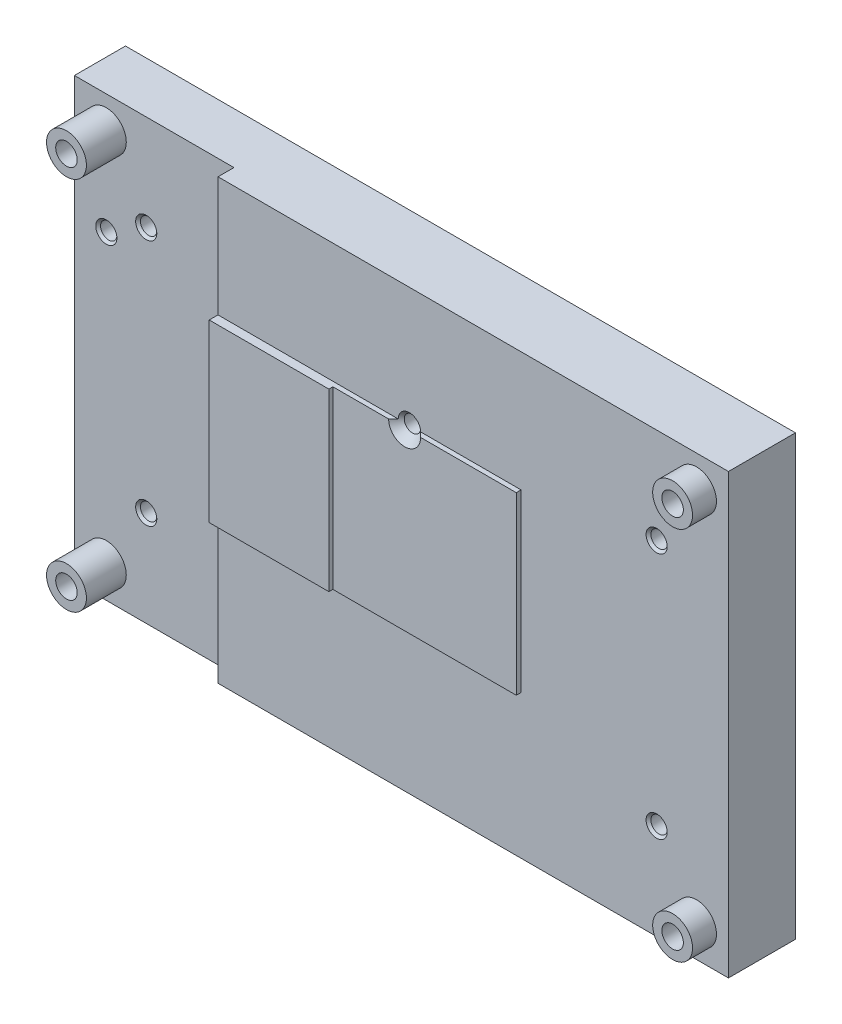
from build123d import *

# Parameters (mm, degrees)
SKETCH1_W                               = 84
SKETCH1_H                               = 55
EXTRUDE1_DEPTH                          = 11.4
F_2_7_2_7_DIAMETER_HOLE1_D              = 2.7
SKETCH6_OUTSIDE_W                       = 106.21
SKETCH6_OUTSIDE_H                       = 77.21
SKETCH6_OUTSIDE_R                       = 2.5
EXTRUDE2_DEPTH                          = 3
SKETCH7_W                               = 15
SKETCH7_H                               = 22
EXTRUDE3_DEPTH                          = 1.1
SKETCH8_W                               = 26.471562954
SKETCH8_H                               = 62.575334395
SKETCH8_R                               = 2.5
EXTRUDE6_DEPTH                          = 2
SKETCH9_W                               = 23
SKETCH9_H                               = 22
EXTRUDE7_DEPTH                          = 0.6
M2_5X0_45_TAPPED_HOLE1_D                = 2.05
CBORE_FOR_M5_HEX_HEAD_BOLT1_D           = 2.7
CBORE_FOR_M5_HEX_HEAD_BOLT1_CBORE_D     = 6
CBORE_FOR_M5_HEX_HEAD_BOLT1_CBORE_DEPTH = 3.5
CHAMFER1_SIZE                           = 0.3


with BuildPart() as part:
    # Sketch1 → Extrude1 (new body)
    with BuildSketch(Plane.XY):
        Rectangle(SKETCH1_W, SKETCH1_H)
    extrude(amount=EXTRUDE1_DEPTH)

    # 2.7 _2.7_ Diameter Hole1 (through all)
    with Locations(Plane.XY.offset(11.4)):
        with Locations((-38, 23.5), (38, 23.5), (38, -23.5), (-38, -23.5)):
            Hole(F_2_7_2_7_DIAMETER_HOLE1_D / 2)

    # Sketch6 outside → Extrude2 (cut)
    with BuildSketch(Plane.XY.offset(11.4)):
        Rectangle(SKETCH6_OUTSIDE_W, SKETCH6_OUTSIDE_H)
        with Locations((-38, 23.5)):
            Circle(SKETCH6_OUTSIDE_R, mode=Mode.SUBTRACT)
        with Locations((-38, -23.5)):
            Circle(SKETCH6_OUTSIDE_R, mode=Mode.SUBTRACT)
        with Locations((38, 23.5)):
            Circle(SKETCH6_OUTSIDE_R, mode=Mode.SUBTRACT)
        with Locations((38, -23.5)):
            Circle(SKETCH6_OUTSIDE_R, mode=Mode.SUBTRACT)
    extrude(amount=-EXTRUDE2_DEPTH, mode=Mode.SUBTRACT)

    # Sketch7 → Extrude3 (add)
    with BuildSketch(Plane.XY.offset(8.4)):
        with Locations((-14.5, 1.5)):
            Rectangle(SKETCH7_W, SKETCH7_H)
    extrude(amount=EXTRUDE3_DEPTH)

    # Sketch8 → Extrude6 (cut)
    with BuildSketch(Plane.XY.offset(8.4)):
        with Locations((-35.235781477, -1.105270853)):
            Rectangle(SKETCH8_W, SKETCH8_H)
        with Locations((-38, -23.5)):
            Circle(SKETCH8_R, mode=Mode.SUBTRACT)
        with Locations((-38, 23.5)):
            Circle(SKETCH8_R, mode=Mode.SUBTRACT)
    extrude(amount=-EXTRUDE6_DEPTH, mode=Mode.SUBTRACT)

    # Sketch9 → Extrude7 (add)
    with BuildSketch(Plane.XY.offset(8.4)):
        with Locations((4.5, 1.5)):
            Rectangle(SKETCH9_W, SKETCH9_H)
    extrude(amount=EXTRUDE7_DEPTH)

    # M2.5x0.45 Tapped Hole1 (through all)
    with Locations(Plane.XY.offset(11.4)):
        with Locations((-33, 15.5), (33, 15.5), (33, -15.5), (-33, -15.5), (2, 12.5), (-38, 12.5)):
            Hole(M2_5X0_45_TAPPED_HOLE1_D / 2)

    # CBORE for M5 Hex Head Bolt1 (through all)
    with Locations(Plane(origin=(0, 0, 0), x_dir=(-1, 0, 0), z_dir=(0, 0, -1))):
        with Locations((-38, 23.5), (-38, -23.5), (38, 23.5), (38, -23.5)):
            CounterBoreHole(CBORE_FOR_M5_HEX_HEAD_BOLT1_D / 2, CBORE_FOR_M5_HEX_HEAD_BOLT1_CBORE_D / 2, CBORE_FOR_M5_HEX_HEAD_BOLT1_CBORE_DEPTH)

    # Chamfer1
    chamfer1_edges = [part.edges().sort_by_distance(p)[0] for p in [
        (-36.975, 12.5, 0),
        (-36.975, 12.5, 6.4),
        (3.025, 12.5, 0),
        (-31.975, -15.5, 0),
        (-31.975, -15.5, 6.4),
        (34.025, -15.5, 8.4),
        (34.025, -15.5, 0),
        (34.025, 15.5, 8.4),
        (34.025, 15.5, 0),
        (-31.975, 15.5, 0),
        (-31.975, 15.5, 6.4),
    ]]
    chamfer(chamfer1_edges, length=CHAMFER1_SIZE)

    # Sketch12 → Cut-Revolve1 (revolve, cut)
    with BuildSketch(Plane.ZY.offset(-2), mode=Mode.PRIVATE) as cut_revolve1_sk:
        Polygon((6.996424716, 12.489411428), (9.321943828, 14.81493054), (9.321943828, 12.489411428), align=None)
    revolve(cut_revolve1_sk.sketch.rotate(Axis((2, 12.489411428, 7.765521671), (0, 0, 1)), 270.302801858), axis=Axis((2, 12.489411428, 7.765521671), (0, 0, 1)), mode=Mode.SUBTRACT)  # turned: the seam where the file's is


solid = part.part
